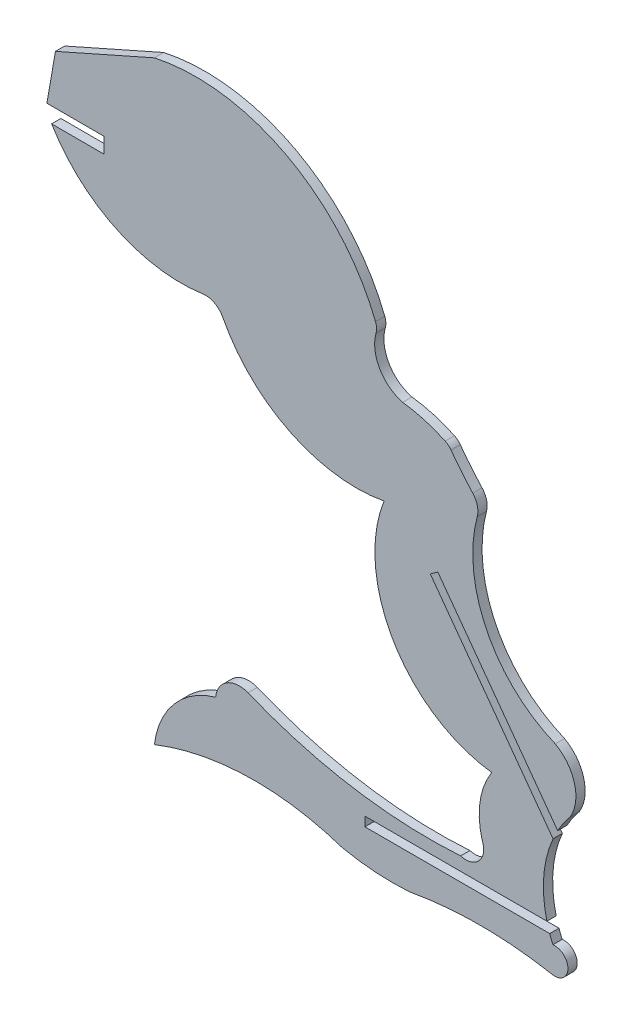
from build123d import *

# Parameters (mm, degrees)
BOSS_EXTRUDE1_DEPTH = 1.524


with BuildPart() as part:
    # Sketch1 → Boss-Extrude1 (new body)
    with BuildSketch(Plane.XY):
        with BuildLine():
            Line((211.523731391, 0), (211.523731391, -2.54))
            Line((211.523731391, -2.54), (202.922883793, -2.527561419))
            ThreePointArc((202.922883793, -2.527561419), (213.554085688, -12.168076331), (227.746163725, -14.300423044))
            ThreePointArc((227.746163725, -14.300423044), (229.650139274, -14.615955212), (231.019640286, -15.975789914))
            ThreePointArc((231.019640286, -15.975789914), (242.141029149, -26.800870517), (257.521078021, -28.879754104))
            ThreePointArc((257.521078021, -28.879754104), (259.093725099, -48.084230478), (275.202983438, -58.65669128))
            ThreePointArc((275.202983438, -58.65669128), (273.284119594, -63.70823493), (273.645185128, -69.099873213))
            ThreePointArc((273.645185128, -69.099873213), (273.142027669, -72.218330377), (270.098113996, -73.062446524))
            ThreePointArc((270.098113996, -73.062446524), (252.314484646, -72.190801616), (235.189633712, -67.316715223))
            ThreePointArc((235.189633712, -67.316715223), (231.709711317, -67.641087637), (229.865155612, -70.609705427))
            ThreePointArc((229.865155612, -70.609705427), (223.057551669, -74.973109583), (219.801437593, -82.374493805))
            ThreePointArc((219.801437593, -82.374493805), (235.189633712, -79.270242267), (250.709830302, -81.627455706))
            ThreePointArc((250.709830302, -81.627455706), (256.183079158, -82.374432464), (261.7070657, -82.374493805))
            ThreePointArc((261.7070657, -82.374493805), (273.347233029, -81.313035156), (284.987400357, -82.374493805))
            ThreePointArc((284.987400357, -82.374493805), (287.719421671, -80.411720704), (285.255147496, -78.121792432))
            ThreePointArc((285.255147496, -78.121792432), (284.981385526, -77.460846026), (284.73300841, -76.789947691))
            Line((284.73300841, -76.789947691), (254.383327933, -76.789947691))
            Line((254.383327933, -76.789947691), (254.383327933, -75.265947691))
            Line((254.383327933, -75.265947691), (284.273085104, -75.265947691))
            ThreePointArc((284.273085104, -75.265947691), (283.749737466, -69.068999992), (285.279905713, -63.041177943))
            Line((285.279905713, -63.041177943), (265.119779794, -35.456547246))
            Line((265.119779794, -35.456547246), (266.350198676, -34.557300131))
            Line((266.350198676, -34.557300131), (286.043441867, -61.503106065))
            ThreePointArc((286.043441867, -61.503106065), (286.989404718, -59.975403718), (288.077109535, -58.54515255))
            ThreePointArc((288.077109535, -58.54515255), (288.80590673, -53.43695911), (285.643381228, -49.359801029))
            ThreePointArc((285.643381228, -49.359801029), (274.368164292, -38.807208416), (272.826055023, -23.441349285))
            ThreePointArc((272.826055023, -23.441349285), (272.839039076, -21.86438539), (272.091685647, -20.475700197))
            ThreePointArc((272.091685647, -20.475700197), (270.245388722, -18.354306042), (268.523028934, -16.131109637))
            ThreePointArc((268.523028934, -16.131109637), (268.090816368, -15.671862862), (267.558783349, -15.333253695))
            ThreePointArc((267.558783349, -15.333253695), (264.150445583, -14.041396316), (260.57978956, -13.309223264))
            ThreePointArc((260.57978956, -13.309223264), (256.794003466, -10.41140001), (256.203064232, -5.680612889))
            ThreePointArc((256.203064232, -5.680612889), (256.293258056, -4.865684219), (256.119145106, -4.06447991))
            ThreePointArc((256.119145106, -4.06447991), (241.521161242, 12.295961664), (219.801437593, 15.299091023))
            Line((219.801437593, 15.299091023), (203.553625304, 8.095778667))
            Line((203.553625304, 8.095778667), (202.1481549, 0.013558997))
            Line((202.1481549, 0.013558997), (211.523731391, 0))
        make_face()
    extrude(amount=BOSS_EXTRUDE1_DEPTH)


solid = part.part
